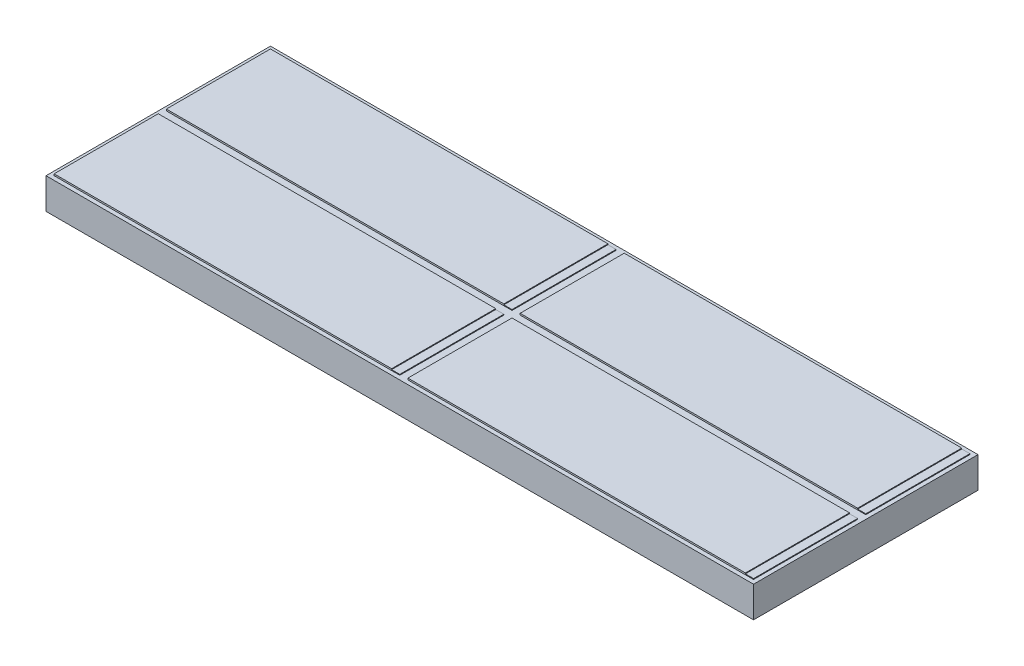
from build123d import *

# Parameters (mm, degrees)
SKETCH1_W           = 43.5
SKETCH1_H           = 13.8
BOSS_EXTRUDE1_DEPTH = 1.9
SKETCH2_W           = 21.25
SKETCH2_H           = 6.4
BOSS_EXTRUDE2_DEPTH = 0.1
SKETCH10_W          = 0.5
SKETCH10_H          = 6.4
CUT_EXTRUDE1_DEPTH  = 0.05


with BuildPart() as part:
    # Sketch1 → Boss-Extrude1 (new body)
    with BuildSketch(Plane(origin=(0, 0, 0), x_dir=(1, 0, 0), z_dir=(0, 1, 0))):
        with Locations((10.452197802, 2.919230769)):
            Rectangle(SKETCH1_W, SKETCH1_H)
    extrude(amount=BOSS_EXTRUDE1_DEPTH)

    # Sketch2 → Boss-Extrude2 (add)
    with BuildSketch(Plane(origin=(0, 1.9, 0), x_dir=(1, 0, 0), z_dir=(0, 1, 0))):
        with Locations((-0.422802198, -0.530769231)):
            Rectangle(SKETCH2_W, SKETCH2_H)
        with Locations((-0.422802198, 6.369230769)):
            Rectangle(SKETCH2_W, SKETCH2_H)
        with Locations((21.327197802, 6.369230769)):
            Rectangle(SKETCH2_W, SKETCH2_H)
        with Locations((21.327197802, -0.530769231)):
            Rectangle(SKETCH2_W, SKETCH2_H)
    extrude(amount=BOSS_EXTRUDE2_DEPTH)

    # Sketch10 → Cut-Extrude1 (cut)
    with BuildSketch(Plane(origin=(0, 2, 0), x_dir=(1, 0, 0), z_dir=(0, 1, 0))):
        with Locations((9.952197802, -0.530769231)):
            Rectangle(SKETCH10_W, SKETCH10_H)
        with Locations((31.702197802, -0.530769231)):
            Rectangle(SKETCH10_W, SKETCH10_H)
        with Locations((9.952197802, 6.369230769)):
            Rectangle(SKETCH10_W, SKETCH10_H)
        with Locations((31.702197802, 6.369230769)):
            Rectangle(SKETCH10_W, SKETCH10_H)
    extrude(amount=-CUT_EXTRUDE1_DEPTH, mode=Mode.SUBTRACT)


solid = part.part
